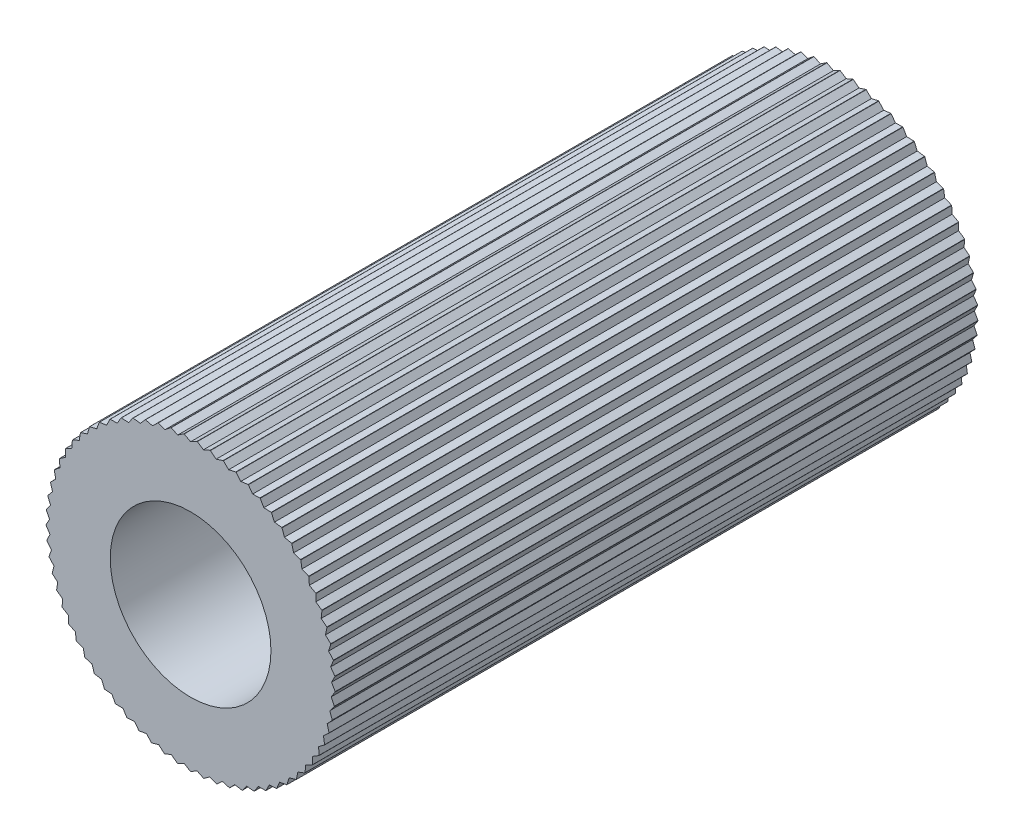
from build123d import *

# Parameters (mm, degrees)
CROQUIS1_R                                 = 2.25
SALIENTE_EXTRUIR1_DEPTH                    = 10
PERFORADOR_PARA_ROSCAR_PARA_MACHO_DE_ROS_D = 2.5
CORTAR_EXTRUIR3_DEPTH                      = 10
MATRIZC1_COUNT                             = 69


with BuildPart() as part:
    # Croquis1 → Saliente-Extruir1 (new body)
    with BuildSketch(Plane.XY):
        Circle(CROQUIS1_R)
    extrude(amount=SALIENTE_EXTRUIR1_DEPTH)

    # Perforador para roscar para macho de roscar para M31 (through all)
    with Locations(Plane.XY.offset(10)):
        with Locations((0, 0)):
            Hole(PERFORADOR_PARA_ROSCAR_PARA_MACHO_DE_ROS_D / 2)

    # Croquis5 → Cortar-Extruir3 (cut)
    with BuildSketch(Plane.XY.offset(10)):
        with BuildLine():
            Line((-0.1, 2.247776679), (0, 2.193017885))
            Line((0, 2.193017885), (0.1, 2.247776679))
            ThreePointArc((0.1, 2.247776679), (0, 2.25), (-0.1, 2.247776679))
        make_face()
    cortar_extruir3 = extrude(amount=-CORTAR_EXTRUIR3_DEPTH, mode=Mode.SUBTRACT)

    # MatrizC1: Cortar-Extruir3 ×69 about axis
    matrizc1_axis = Axis((0, 0, 0), (0, 0, 1))
    for i in range(1, MATRIZC1_COUNT):
        add(cortar_extruir3.rotate(matrizc1_axis, i * 360 / MATRIZC1_COUNT), mode=Mode.SUBTRACT)


solid = part.part
